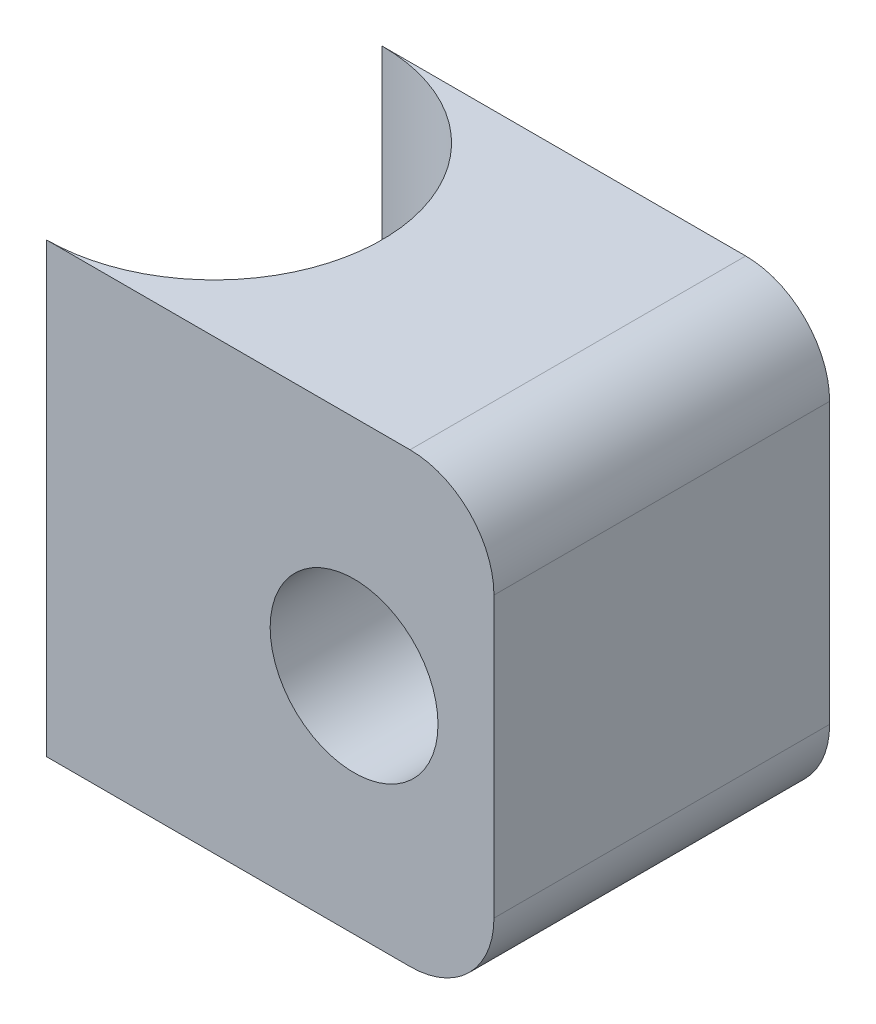
from build123d import *

# Parameters (mm, degrees)
SKETCH1_W           = 8
SKETCH1_H           = 8
BOSS_EXTRUDE1_DEPTH = 6
SKETCH2_R           = 1.5
CUT_EXTRUDE1_DEPTH  = 6
CUT_EXTRUDE3_DEPTH  = 9
SKETCH4_R           = 1.5
BOSS_EXTRUDE3_DEPTH = 1
FILLET1_R           = 1.5


with BuildPart() as part:
    # Sketch1 → Boss-Extrude1 (new body)
    with BuildSketch(Plane.XY):
        with Locations((4, 4)):
            Rectangle(SKETCH1_W, SKETCH1_H)
    extrude(amount=BOSS_EXTRUDE1_DEPTH)

    # Sketch2 → Cut-Extrude1 (cut)
    with BuildSketch(Plane(origin=(0, 0, 0), x_dir=(-1, 0, 0), z_dir=(0, 0, -1))):
        with Locations((-5.5, 4)):
            Circle(SKETCH2_R)
    extrude(amount=-CUT_EXTRUDE1_DEPTH, mode=Mode.SUBTRACT)

    # Sketch3 → Cut-Extrude3 (cut)
    with BuildSketch(Plane.XZ):
        with BuildLine():
            Line((0, 6), (0, 0))
            ThreePointArc((0, 0), (3, 3), (0, 6))
        make_face()
    extrude(amount=-CUT_EXTRUDE3_DEPTH, mode=Mode.SUBTRACT)

    # Sketch4 → Boss-Extrude3 (add)
    with BuildSketch(Plane(origin=(0, 0, 0), x_dir=(-1, 0, 0), z_dir=(0, 0, -1))):
        with Locations((-5.5, 4)):
            Circle(SKETCH4_R)
    extrude(amount=-BOSS_EXTRUDE3_DEPTH)

    # Fillet1
    fillet1_edges = [part.edges().sort_by_distance(p)[0] for p in [
        (8, 8, 3),
        (8, 0, 3),
    ]]
    fillet(fillet1_edges, radius=FILLET1_R)


solid = part.part
